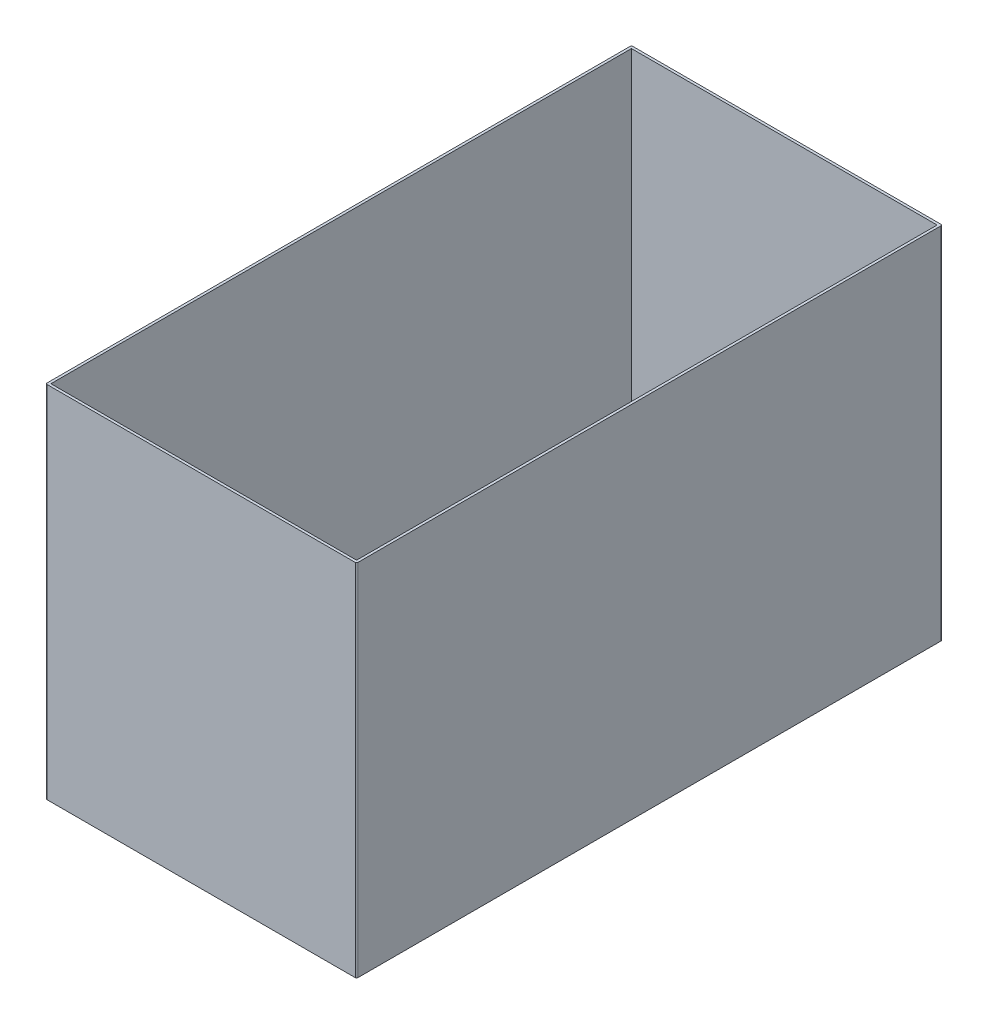
from build123d import *

# Parameters (mm, degrees)
SKETCH1_W           = 12.1
SKETCH1_H           = 22.8
SKETCH1_W_2         = 11.9
SKETCH1_H_2         = 22.6
EXTRUDE_THIN1_DEPTH = 7
FILLET1_R           = 0.05


with BuildPart() as part:
    # Sketch1 → Extrude-Thin1 (new body, symmetric)
    with BuildSketch(Plane(origin=(0, 0, 0), x_dir=(1, 0, 0), z_dir=(0, 1, 0))):
        Rectangle(SKETCH1_W, SKETCH1_H)
        Rectangle(SKETCH1_W_2, SKETCH1_H_2, mode=Mode.SUBTRACT)
    extrude(amount=EXTRUDE_THIN1_DEPTH, both=True)

    # Fillet1
    fillet1_edges = [part.edges().sort_by_distance(p)[0] for p in [
        (-6.05, 0, -11.4),
        (6.05, 0, -11.4),
        (6.05, 0, 11.4),
        (-6.05, 0, 11.4),
    ]]
    fillet(fillet1_edges, radius=FILLET1_R)


solid = part.part
